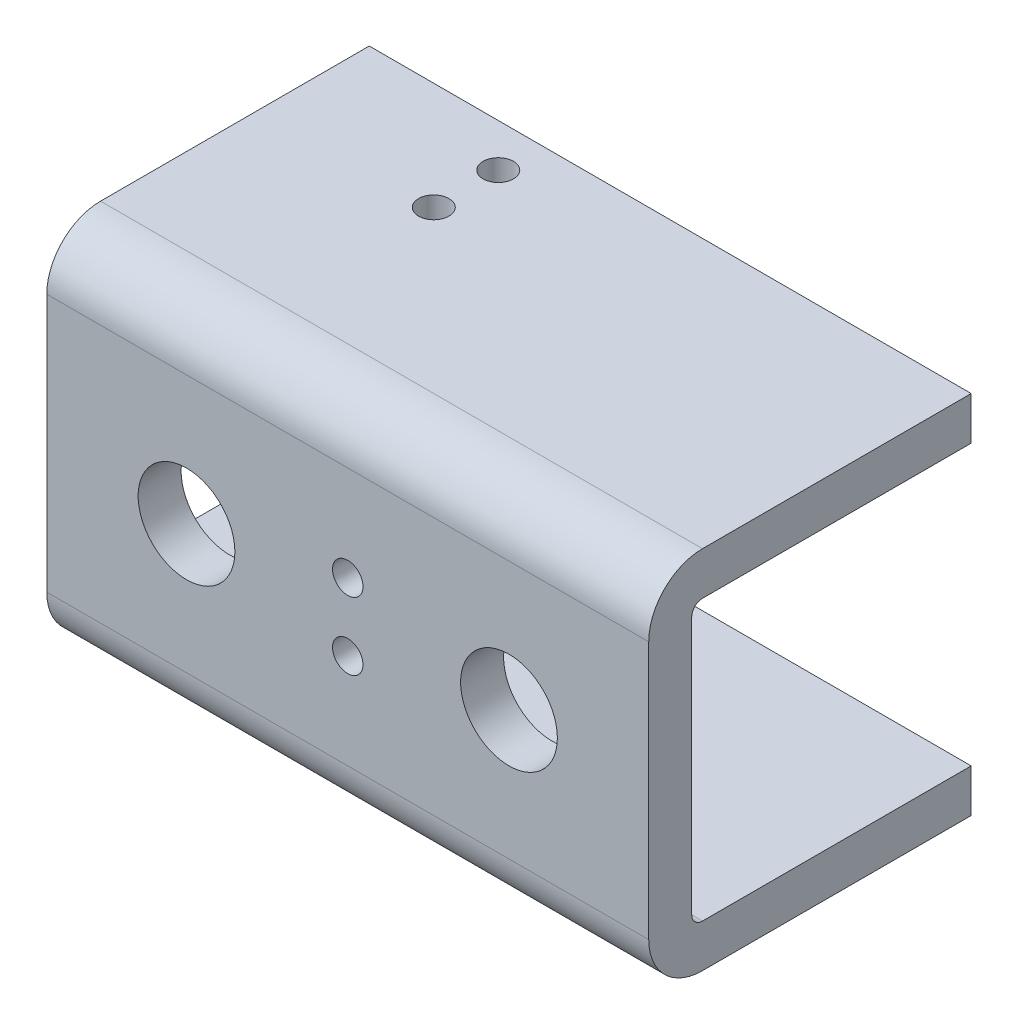
from build123d import *

# Parameters (mm, degrees)
SKETCH1_W                   = 88.9
SKETCH1_H                   = 53.975
BOSS_EXTRUDE1_DEPTH         = 20.6375
FILLET1_R                   = 7.9375
SKETCH3_W                   = 88.9
SKETCH3_H                   = 53.975
BOSS_EXTRUDE2_DEPTH         = 6.35
SHELL1_T                    = -6.35
SKETCH2_R                   = 7.14375
CUT_EXTRUDE1_DEPTH          = 47.625
F_16_0_177_DIAMETER_HOLE1_D = 4.4958
F_16_0_177_DIAMETER_HOLE2_D = 4.4958


with BuildPart() as part:
    # Sketch1 → Boss-Extrude1 (new body, symmetric)
    with BuildSketch(Plane.XY):
        Rectangle(SKETCH1_W, SKETCH1_H)
    extrude(amount=BOSS_EXTRUDE1_DEPTH, both=True)

    # Fillet1
    fillet1_edges = [part.edges().sort_by_distance(p)[0] for p in [
        (0, 26.9875, 20.6375),
        (0, -26.9875, 20.6375),
    ]]
    fillet(fillet1_edges, radius=FILLET1_R)

    # Sketch3 → Boss-Extrude2 (add)
    with BuildSketch(Plane(origin=(0, 0, -20.6375), x_dir=(-1, 0, 0), z_dir=(0, 0, -1))):
        Rectangle(SKETCH3_W, SKETCH3_H)
    extrude(amount=BOSS_EXTRUDE2_DEPTH)

    # Shell1
    shell1_openings = [part.faces().sort_by_distance(p)[0] for p in [
        (0, 0, -26.9875),
        (44.45, 0, 2.664636692),
        (-44.45, 0, 2.664636692),
    ]]
    offset(amount=SHELL1_T, openings=shell1_openings, kind=Kind.INTERSECTION)

    # Sketch2 → Cut-Extrude1 (cut)
    with BuildSketch(Plane.XY.offset(20.6375)):
        with Locations((-23.8125, 0)):
            Circle(SKETCH2_R)
        with Locations((23.8125, 0)):
            Circle(SKETCH2_R)
    extrude(amount=-CUT_EXTRUDE1_DEPTH, mode=Mode.SUBTRACT)

    # #16 (0.177) Diameter Hole1 (through all)
    with Locations(Plane(origin=(0, 26.9875, 0), x_dir=(1, 0, 0), z_dir=(0, 1, 0))):
        with Locations((-19.05, 11.1125), (-19.05, 20.6375)):
            Hole(F_16_0_177_DIAMETER_HOLE1_D / 2)

    # #16 (0.177) Diameter Hole2 (through all)
    with Locations(Plane.XY.offset(20.6375)):
        with Locations((0, -5), (0, 5)):
            Hole(F_16_0_177_DIAMETER_HOLE2_D / 2)


solid = part.part
